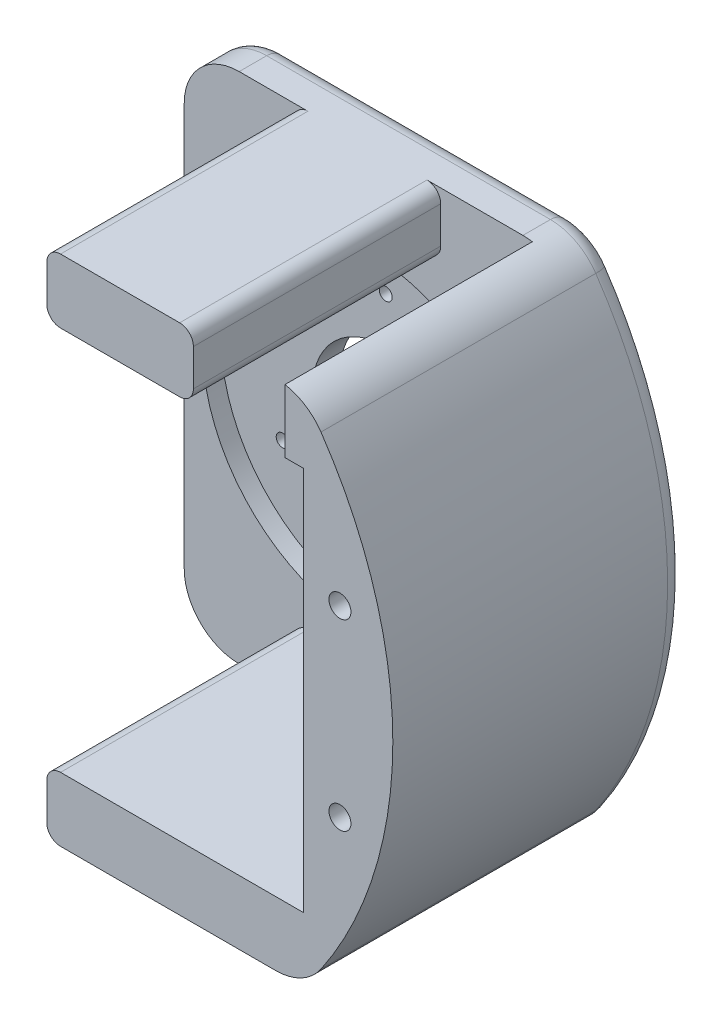
from build123d import *

# Parameters (mm, degrees)
SKETCH_1_R              = 8
EXTRUDE_1_DEPTH         = 3
HOLE_WIZARD_M1_21_D     = 1.4
HOLE_WIZARD_M1_21_DEPTH = 9.579397567
HOLE_WIZARD_M1_21_TIP   = 0.420602433
EXTRUDE_START           = 2
SKETCH_1_3_R            = 18
EXTRUDE_2_DEPTH         = 2
EXTRUDE_START_2         = 27
SKETCH_2_W              = 16
SKETCH_2_H              = 7
EXTRUDE_3_DEPTH         = 27
FILLET_1_R              = 6
FILLET_3_R              = 1.5
HOLE_WIZARD_M21_D       = 2.4
HOLE_WIZARD_M21_DEPTH   = 9.278967257
HOLE_WIZARD_M21_TIP     = 0.721032743
HOLE_WIZARD_M1_22_D     = 1.4
HOLE_WIZARD_M1_22_DEPTH = 9.579397567
HOLE_WIZARD_M1_22_TIP   = 0.420602433
FILLET_4_R              = 2


with BuildPart() as part:
    # Эскиз1 → Бобышка-Вытянуть1 (new body)
    with BuildSketch(Plane.XY):
        with BuildLine():
            Line((0, 56), (0, 0))
            Line((0, 0), (40, 0))
            ThreePointArc((40, 0), (49.772170092, 28), (40, 56))
            Line((40, 56), (0, 56))
        make_face()
        with Locations((20, 28)):
            Circle(SKETCH_1_R, mode=Mode.SUBTRACT)
    extrude(amount=-EXTRUDE_1_DEPTH)

    # Отверстие с зазором M1.21
    with Locations(Plane.XY):
        with Locations((20, 41), (31.258330249, 34.5), (31.258330249, 21.5), (20, 15), (8.741669751, 21.5), (8.741669751, 34.5)):
            Hole(HOLE_WIZARD_M1_21_D / 2, depth=HOLE_WIZARD_M1_21_DEPTH)
            with Locations((0, 0, -(HOLE_WIZARD_M1_21_DEPTH + HOLE_WIZARD_M1_21_TIP / 2))):  # 118° drill point
                Cone(0, HOLE_WIZARD_M1_21_D / 2, HOLE_WIZARD_M1_21_TIP, mode=Mode.SUBTRACT)

    # Эскиз1<3> → Бобышка-Вытянуть2 (add)
    with BuildSketch(Plane.XY.offset(EXTRUDE_START)):
        with BuildLine():
            Line((0, 56), (0, 0))
            Line((0, 0), (40, 0))
            ThreePointArc((40, 0), (49.772170092, 28), (40, 56))
            Line((40, 56), (0, 56))
        make_face()
        with Locations((20, 28)):
            Circle(SKETCH_1_3_R, mode=Mode.SUBTRACT)
    extrude(amount=-EXTRUDE_2_DEPTH)

    # Эскиз2 → Бобышка-Вытянуть3 (add)
    with BuildSketch(Plane.XY.offset(2).offset(EXTRUDE_START_2)):
        with BuildLine():
            Line((40, 0), (12, 0))
            Line((12, 0), (12, 7))
            Line((12, 7), (40, 7))
            Line((40, 7), (40, 49))
            Line((40, 49), (38, 49))
            Line((38, 49), (38, 56))
            Line((38, 56), (40, 56))
            ThreePointArc((40, 56), (49.772170092, 28), (40, 0))
        make_face()
        with Locations((20, 52.5)):
            Rectangle(SKETCH_2_W, SKETCH_2_H)
    extrude(amount=-EXTRUDE_3_DEPTH)

    # Скругление1
    fillet_1_edges = [part.edges().sort_by_distance(p)[0] for p in [
        (40, 56, 13),
        (40, 0, 13),
        (0, 0, -0.5),
        (0, 56, -0.5),
    ]]
    fillet(fillet_1_edges, radius=FILLET_1_R)

    # Скругление3
    fillet_3_edges = [part.edges().sort_by_distance(p)[0] for p in [
        (12, 0, 15.5),
        (12, 7, 15.5),
        (28, 56, 15.5),
        (28, 49, 15.5),
        (12, 56, 15.5),
        (12, 49, 15.5),
    ]]
    fillet(fillet_3_edges, radius=FILLET_3_R)

    # Отверстие с зазором M21
    with Locations(Plane.XY.offset(29)):
        with Locations((44, 38), (44, 18)):
            Hole(HOLE_WIZARD_M21_D / 2, depth=HOLE_WIZARD_M21_DEPTH)
            with Locations((0, 0, -(HOLE_WIZARD_M21_DEPTH + HOLE_WIZARD_M21_TIP / 2))):  # 118° drill point
                Cone(0, HOLE_WIZARD_M21_D / 2, HOLE_WIZARD_M21_TIP, mode=Mode.SUBTRACT)

    # Отверстие с зазором M1.22
    with Locations(Plane.ZY.offset(-12)):
        with Locations((20, 52.240238149), (11, 52.240238149), (20, 3.759761857), (11, 3.759761857)):
            Hole(HOLE_WIZARD_M1_22_D / 2, depth=HOLE_WIZARD_M1_22_DEPTH)
            with Locations((0, 0, -(HOLE_WIZARD_M1_22_DEPTH + HOLE_WIZARD_M1_22_TIP / 2))):  # 118° drill point
                Cone(0, HOLE_WIZARD_M1_22_D / 2, HOLE_WIZARD_M1_22_TIP, mode=Mode.SUBTRACT)

    # Скругление4
    fillet_4_edges = [part.edges().sort_by_distance(p)[0] for p in [
        (39.775753154, 0.693980197, -3),
        (21.487327234, 0, -3),
        (1.757359313, 1.757359313, -3),
        (0, 28, -3),
        (1.757359313, 54.242640687, -3),
        (21.487327234, 56, -3),
        (39.775753154, 55.306019803, -3),
        (49.772170092, 28, -3),
    ]]
    fillet(fillet_4_edges, radius=FILLET_4_R)


solid = part.part
